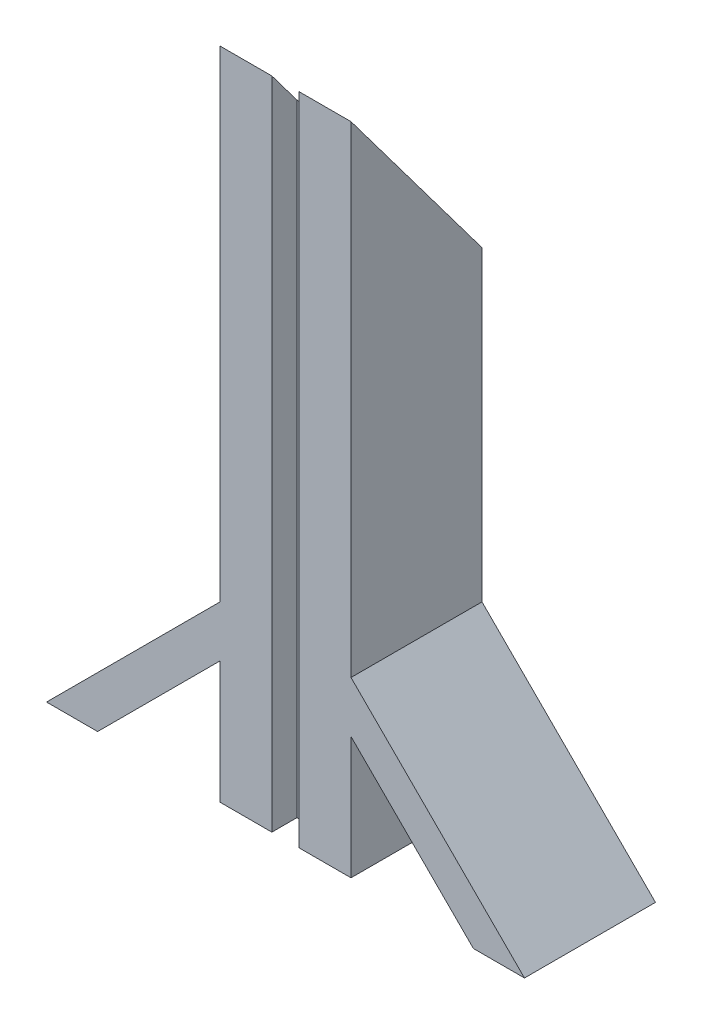
from build123d import *

# Parameters (mm, degrees)
SKETCH1_W           = 30
SKETCH1_H           = 30
BOSS_EXTRUDE1_DEPTH = 150
BOSS_EXTRUDE2_DEPTH = 15
CUT_EXTRUDE1_DEPTH  = 70.736433232
SKETCH4_W           = 6.25
SKETCH4_H           = 11.445552978
CUT_EXTRUDE2_DEPTH  = 151


with BuildPart() as part:
    # Sketch1 → Boss-Extrude1 (new body)
    with BuildSketch(Plane(origin=(0, 0, 0), x_dir=(1, 0, 0), z_dir=(0, 1, 0))):
        Rectangle(SKETCH1_W, SKETCH1_H)
    extrude(amount=BOSS_EXTRUDE1_DEPTH)

    # Sketch2 → Boss-Extrude2 (add, symmetric)
    with BuildSketch(Plane.XY):
        Polygon((15, 39.736433232), (54.736433232, 0), (43.033817395, 0), (15, 28.033817395), align=None)
    boss_extrude2 = extrude(amount=BOSS_EXTRUDE2_DEPTH, both=True)

    # Mirror1: Boss-Extrude2 across plane
    add(boss_extrude2.mirror(Plane(origin=(0, 0, 0), x_dir=(0, 0, 1), z_dir=(1, 0, 0))))

    # Sketch3 → Cut-Extrude1 (cut, through all)
    with BuildSketch(Plane.ZY.offset(15)):
        Polygon((15, 150), (-15, 110), (-15, 150), align=None)
    extrude(amount=-CUT_EXTRUDE1_DEPTH, mode=Mode.SUBTRACT)

    # Sketch4 → Cut-Extrude2 (cut, through all)
    with BuildSketch(Plane.XZ):
        with Locations((0, 15)):
            Rectangle(SKETCH4_W, SKETCH4_H)
    extrude(amount=-CUT_EXTRUDE2_DEPTH, mode=Mode.SUBTRACT)


solid = part.part
